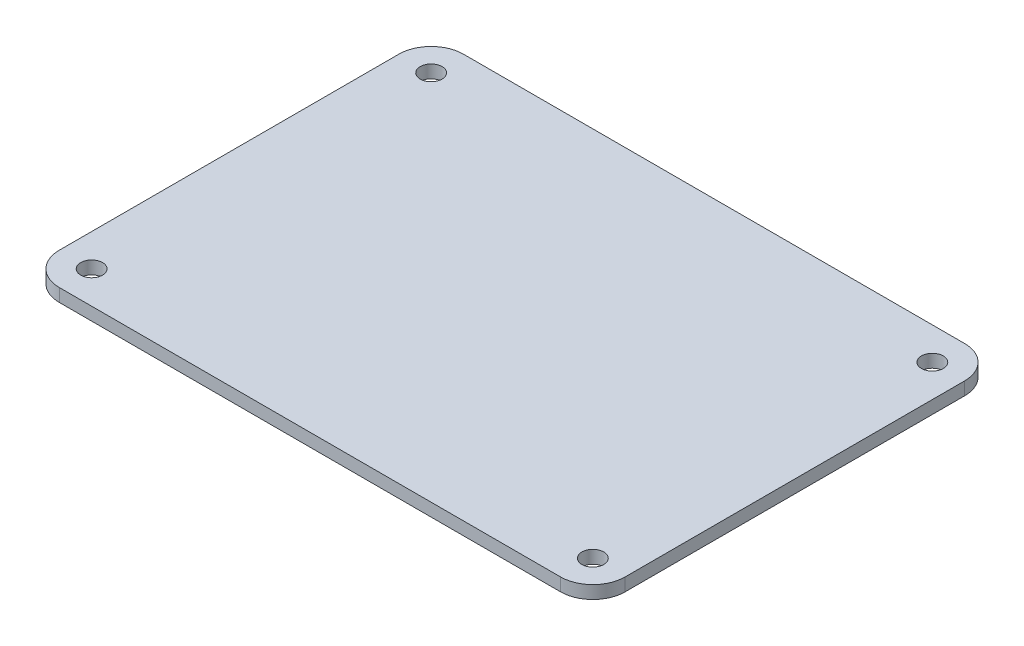
from build123d import *

# Parameters (mm, degrees)
SKETCH1_W           = 70
SKETCH1_H           = 50
BOSS_EXTRUDE1_DEPTH = 1.6
SKETCH2_R           = 1.35
CUT_EXTRUDE1_DEPTH  = 2.6
FILLET1_R           = 4


with BuildPart() as part:
    # Sketch1 → Boss-Extrude1 (new body)
    with BuildSketch(Plane(origin=(0, 0, 0), x_dir=(1, 0, 0), z_dir=(0, 1, 0))):
        Rectangle(SKETCH1_W, SKETCH1_H)
    extrude(amount=BOSS_EXTRUDE1_DEPTH)

    # Sketch2 → Cut-Extrude1 (cut, through all)
    with BuildSketch(Plane(origin=(0, 1.6, 0), x_dir=(1, 0, 0), z_dir=(0, 1, 0))):
        with Locations((-31, 21)):
            Circle(SKETCH2_R)
        with Locations((31, 21)):
            Circle(SKETCH2_R)
        with Locations((31, -21)):
            Circle(SKETCH2_R)
        with Locations((-31, -21)):
            Circle(SKETCH2_R)
    extrude(amount=-CUT_EXTRUDE1_DEPTH, mode=Mode.SUBTRACT)

    # Fillet1
    fillet1_edges = [part.edges().sort_by_distance(p)[0] for p in [
        (35, 0.8, 25),
        (-35, 0.8, 25),
        (-35, 0.8, -25),
        (35, 0.8, -25),
    ]]
    fillet(fillet1_edges, radius=FILLET1_R)


solid = part.part
